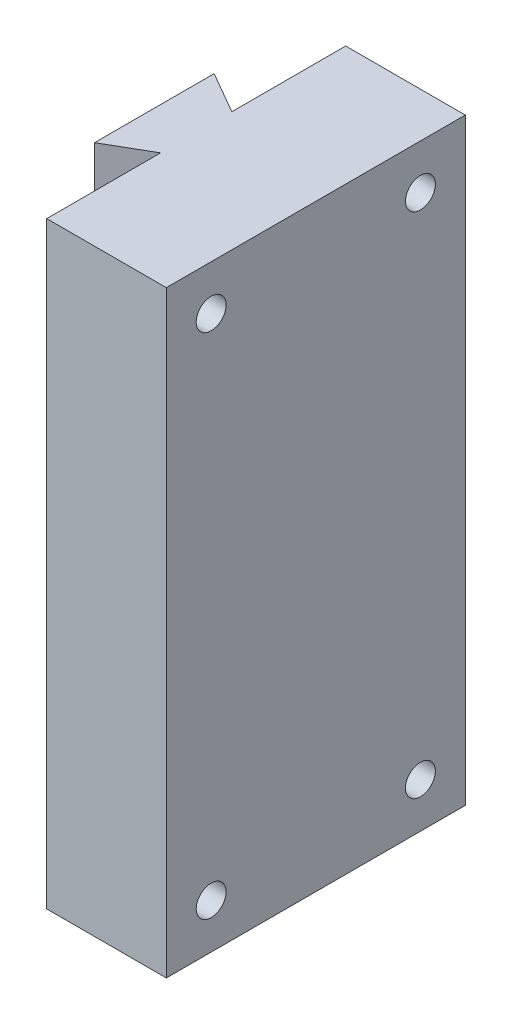
from build123d import *

# Parameters (mm, degrees)
BOSS_EXTRUDE1_DEPTH = 100
SKETCH2_R           = 2.5
CUT_EXTRUDE1_DEPTH  = 10


with BuildPart() as part:
    # Sketch1 → Boss-Extrude1 (new body)
    with BuildSketch(Plane(origin=(0, 0, 0), x_dir=(1, 0, 0), z_dir=(0, 1, 0))):
        Polygon((-27, 10), (-27, -10), (-20, -5.958548116), (-20, -25), (0, -25), (0, 25), (-20, 25), (-20, 5.958548116), align=None)
    extrude(amount=BOSS_EXTRUDE1_DEPTH)

    # Sketch2 → Cut-Extrude1 (cut)
    with BuildSketch(Plane(origin=(0, 0, 0), x_dir=(0, 0, -1), z_dir=(1, 0, 0))):
        with Locations((-17.5, 92.5)):
            Circle(SKETCH2_R)
        with Locations((-17.5, 7.5)):
            Circle(SKETCH2_R)
        with Locations((17.5, 7.5)):
            Circle(SKETCH2_R)
        with Locations((17.5, 92.5)):
            Circle(SKETCH2_R)
    extrude(amount=-CUT_EXTRUDE1_DEPTH, mode=Mode.SUBTRACT)


solid = part.part
